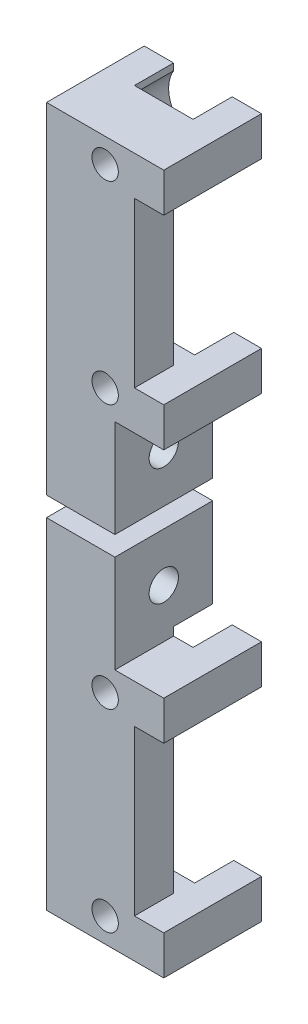
from build123d import *

# Parameters (mm, degrees)
SKETCH7_W           = 12
SKETCH7_H           = 24.8
MAIN_DEPTH          = 5
SKETCH8_R           = 1.35
HOLES_DEPTH         = 11
SKETCH16_W          = 6
SKETCH16_H          = 16.8
FIXEXTRUSION_DEPTH  = 13
SKETCH17_W          = 6
SKETCH17_H          = 24.8
CUT_EXTRUDE1_DEPTH  = 4
SKETCH18_W          = 3
SKETCH18_H          = 16.8
CUT_EXTRUDE2_DEPTH  = 5
BOSS_EXTRUDE1_DEPTH = 10
SKETCH20_R          = 1.5
CUT_EXTRUDE3_DEPTH  = 9
SKETCH21_R          = 3.5
CUT_EXTRUDE4_DEPTH  = 4


with BuildPart() as part:
    # Sketch7 → Main (new body, symmetric)
    with BuildSketch(Plane.XY.offset(-150)):
        with Locations((0, 12.4)):
            Rectangle(SKETCH7_W, SKETCH7_H)
    extrude(amount=MAIN_DEPTH, both=True)

    # Sketch8 → Holes (cut, through all)
    with BuildSketch(Plane.XY.offset(-145)):
        with Locations((0, 22.3)):
            Circle(SKETCH8_R)
        with Locations((0, 2.5)):
            Circle(SKETCH8_R)
    extrude(amount=-HOLES_DEPTH, mode=Mode.SUBTRACT)

    # Sketch16 → FixExtrusion (cut, through all)
    with BuildSketch(Plane(origin=(6, 0, 0), x_dir=(0, 0, -1), z_dir=(1, 0, 0))):
        with Locations((152, 12.4)):
            Rectangle(SKETCH16_W, SKETCH16_H)
    extrude(amount=-FIXEXTRUSION_DEPTH, mode=Mode.SUBTRACT)

    # Sketch17 → Cut-Extrude1 (cut)
    with BuildSketch(Plane(origin=(0, 0, -155), x_dir=(-1, 0, 0), z_dir=(0, 0, -1))):
        with Locations((0, 12.4)):
            Rectangle(SKETCH17_W, SKETCH17_H)
    extrude(amount=-CUT_EXTRUDE1_DEPTH, mode=Mode.SUBTRACT)

    # Sketch18 → Cut-Extrude2 (cut, through all)
    with BuildSketch(Plane(origin=(0, 0, -149), x_dir=(-1, 0, 0), z_dir=(0, 0, -1))):
        with Locations((-4.5, 12.4)):
            Rectangle(SKETCH18_W, SKETCH18_H)
    extrude(amount=-CUT_EXTRUDE2_DEPTH, mode=Mode.SUBTRACT)

    # Sketch19 → Boss-Extrude1 (add)
    with BuildSketch(Plane.XZ):
        Polygon((1, -155), (-6, -155), (-6, -151.45), (-7, -151.45), (-7, -148.55), (-6, -148.55), (-6, -145), (1, -145), align=None)
    extrude(amount=BOSS_EXTRUDE1_DEPTH)

    # Sketch20 → Cut-Extrude3 (cut, through all)
    with BuildSketch(Plane(origin=(1, 0, 0), x_dir=(0, 0, -1), z_dir=(1, 0, 0))):
        with Locations((150, -5)):
            Circle(SKETCH20_R)
    extrude(amount=-CUT_EXTRUDE3_DEPTH, mode=Mode.SUBTRACT)

    # Sketch21 → Cut-Extrude4 (cut)
    with BuildSketch(Plane(origin=(0, 0, -155), x_dir=(-1, 0, 0), z_dir=(0, 0, -1))):
        with Locations((0, 2.5)):
            Circle(SKETCH21_R)
        with Locations((0, 22.3)):
            Circle(SKETCH21_R)
    extrude(amount=-CUT_EXTRUDE4_DEPTH, mode=Mode.SUBTRACT)


with BuildPart() as body_2:
    # Mirror2: mirrored copy
    add(part.part.mirror(Plane(origin=(0, -11, 0), x_dir=(0, 0, 1), z_dir=(0, -1, 0))))


solid = Compound([part.part, body_2.part])
